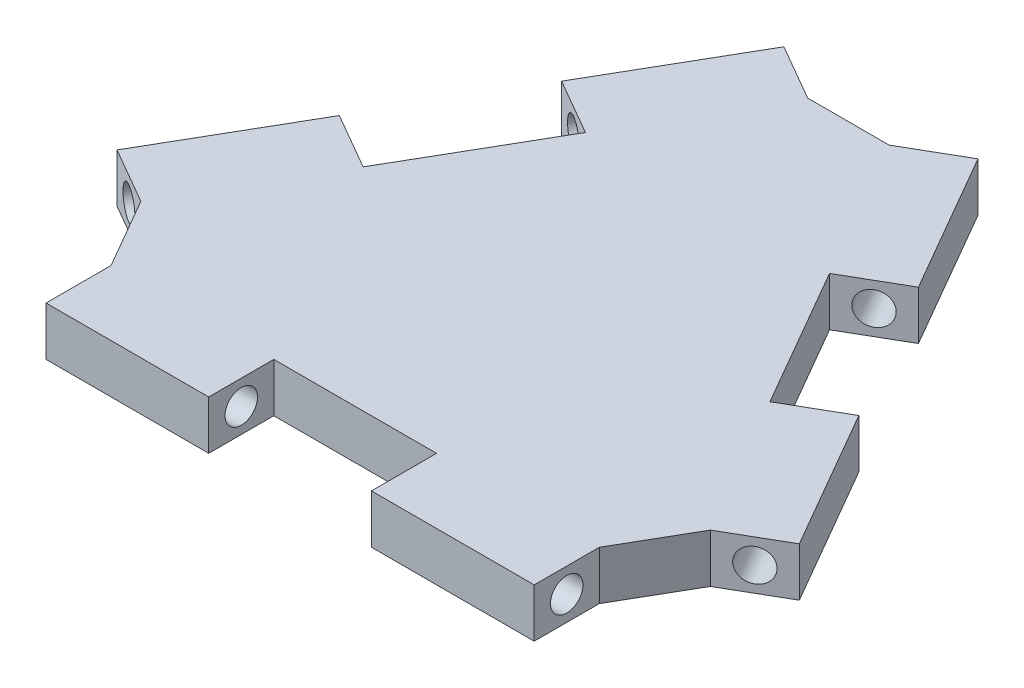
from build123d import *

# Parameters (mm, degrees)
BOSS_EXTRUDE1_DEPTH = 3
CUT_EXTRUDE1_DEPTH  = 20
SKETCH4_R           = 1
CUT_EXTRUDE2_DEPTH  = 63
SKETCH5_R           = 1
CUT_EXTRUDE3_DEPTH  = 36


with BuildPart() as part:
    # Sketch1 → Boss-Extrude1 (new body)
    with BuildSketch(Plane(origin=(0, 0, 0), x_dir=(1, 0, 0), z_dir=(0, 1, 0))):
        Polygon((0, 34.641016151), (-2.5, 30.310889132), (-5.964101615, 32.310889132), (-10.964101615, 23.650635095), (-7.5, 21.650635095), (-12.5, 12.990381057), (-15.964101615, 14.990381057), (-20.964101615, 6.330127019), (-17.5, 4.330127019), (-20, 0), (-15, 0), (-15, -4), (-5, -4), (-5, 0), (5, 0), (5, -4), (15, -4), (15, 0), (20, 0), (17.5, 4.330127019), (20.964101615, 6.330127019), (15.964101615, 14.990381057), (12.5, 12.990381057), (7.5, 21.650635095), (10.964101615, 23.650635095), (5.964101615, 32.310889132), (2.5, 30.310889132), align=None)
    extrude(amount=BOSS_EXTRUDE1_DEPTH)

    # Sketch3 → Cut-Extrude1 (cut)
    with BuildSketch(Plane(origin=(0, 3, 0), x_dir=(1, 0, 0), z_dir=(0, 1, 0))):
        Polygon((-20, 0), (-15, 0), (-17.5, 4.330127019), align=None)
        Polygon((0, 34.641016151), (-2.5, 30.310889132), (2.5, 30.310889132), align=None)
        Polygon((20, 0), (17.5, 4.330127019), (15, 0), align=None)
    extrude(amount=-CUT_EXTRUDE1_DEPTH, mode=Mode.SUBTRACT)

    # Sketch4 → Cut-Extrude2 (cut)
    with BuildSketch(Plane(origin=(15, 0, 0), x_dir=(0, 0, -1), z_dir=(1, 0, 0))):
        with Locations((-2, 1.5)):
            Circle(SKETCH4_R)
    extrude(amount=-CUT_EXTRUDE2_DEPTH, mode=Mode.SUBTRACT)

    # Sketch5 → Cut-Extrude3 (cut)
    with BuildSketch(Plane(origin=(2.5, 0, 4.330127019), x_dir=(0.866025404, 0, -0.5), z_dir=(0.5, 0, 0.866025404))):
        with Locations((19.320508076, 1.5)):
            Circle(SKETCH5_R)
    cut_extrude3 = extrude(amount=-CUT_EXTRUDE3_DEPTH, mode=Mode.SUBTRACT)

    # Mirror1: Cut-Extrude3 across plane
    add(cut_extrude3.mirror(Plane(origin=(0, 0, 0), x_dir=(0, 0, 1), z_dir=(1, 0, 0))), mode=Mode.SUBTRACT)


solid = part.part
